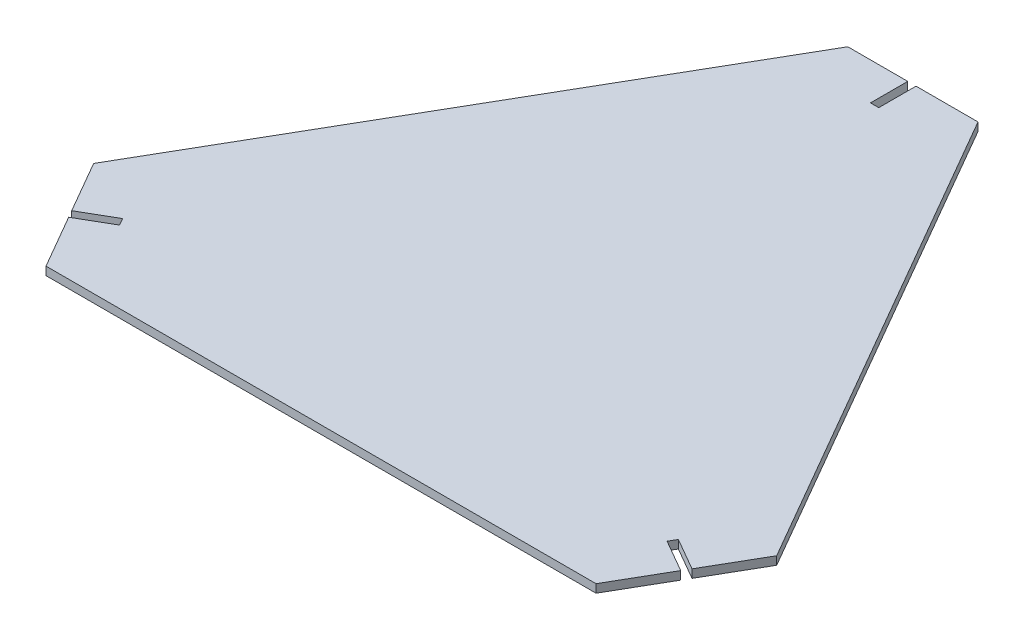
from build123d import *

# Parameters (mm, degrees)
SALIENTE_EXTRUIR1_DEPTH = 1.5
CORTAR_EXTRUIR1_DEPTH   = 3
MATRIZC1_COUNT          = 3
CORTAR_EXTRUIR4_REACH   = 5


with BuildPart() as part:
    # Croquis1 → Saliente-Extruir1 (new body, symmetric)
    with BuildSketch(Plane(origin=(0, 0, 0), x_dir=(1, 0, 0), z_dir=(0, 1, 0))):
        with BuildLine():
            Line((-129.903810568, -55), (-17.320508076, 140))
            ThreePointArc((-17.320508076, 140), (0, 150), (17.320508076, 140))
            Line((17.320508076, 140), (129.903810568, -55))
            ThreePointArc((129.903810568, -55), (129.903810568, -75), (112.583302492, -85))
            Line((112.583302492, -85), (-112.583302492, -85))
            ThreePointArc((-112.583302492, -85), (-129.903810568, -75), (-129.903810568, -55))
        make_face()
    extrude(amount=SALIENTE_EXTRUIR1_DEPTH, both=True)

    # Croquis2 → Cortar-Extruir1 (cut)
    with BuildSketch(Plane(origin=(0, 1.5, 0), x_dir=(1, 0, 0), z_dir=(0, 1, 0))):
        Polygon((107.503175473, -63.799038106), (109.003175473, -61.200961894), (100.342921435, -56.200961894), (98.842921435, -58.799038106), align=None)
        Polygon((113.784264386, -59.919872981), (116.382340598, -61.419872981), (121.382340598, -52.759618943), (118.784264386, -51.259618943), align=None)
        Polygon((117.663429511, -66.200961894), (116.163429511, -68.799038106), (124.823683549, -73.799038106), (126.323683549, -71.200961894), align=None)
        Polygon((111.382340598, -70.080127019), (108.784264386, -68.580127019), (103.784264386, -77.240381057), (106.382340598, -78.740381057), align=None)
    cortar_extruir1 = extrude(amount=-CORTAR_EXTRUIR1_DEPTH, mode=Mode.SUBTRACT)

    # MatrizC1: Cortar-Extruir1 ×3 about axis
    matrizc1_axis = Axis((-0.369121776, 0, -0.213112557), (0, 1, 0))
    for i in range(1, MATRIZC1_COUNT):
        add(cortar_extruir1.rotate(matrizc1_axis, i * 360 / MATRIZC1_COUNT), mode=Mode.SUBTRACT)

    # Croquis5 → Cortar-Extruir4 (cut, up to next)
    with BuildSketch(Plane(origin=(0, 1.5, 0), x_dir=(1, 0, 0), z_dir=(0, 1, 0)), mode=Mode.PRIVATE) as cortar_extruir4_sk1:
        Polygon((-123.633404248, -44.139337671), (-112.772507939, -62.950961894), (-109.741419026, -61.200961894), (-108.241419026, -63.799038106), (-111.272507939, -65.549038106), (-100.042489853, -85), (-147.224318643, -85), align=None)
    cortar_extruir4_tool1 = extrude(cortar_extruir4_sk1.sketch, amount=-CORTAR_EXTRUIR4_REACH, mode=Mode.PRIVATE) & part.part
    add(cortar_extruir4_tool1.solids().sort_by_distance((-123.491961, 1.5, 71.293524))[0], mode=Mode.SUBTRACT)
    # Croquis5 → Cortar-Extruir4 (cut, up to next)
    with BuildSketch(Plane(origin=(0, 1.5, 0), x_dir=(1, 0, 0), z_dir=(0, 1, 0)), mode=Mode.PRIVATE) as cortar_extruir4_sk2:
        Polygon((-1.869121776, 129.139337671), (-23.590914395, 129.139337671), (0, 170), (23.590914395, 129.139337671), (1.130878224, 129.139337671), (1.130878224, 125.639337671), (-1.869121776, 125.639337671), align=None)
    cortar_extruir4_tool2 = extrude(cortar_extruir4_sk2.sketch, amount=-CORTAR_EXTRUIR4_REACH, mode=Mode.PRIVATE) & part.part
    add(cortar_extruir4_tool2.solids().sort_by_distance((-0.003977, 1.5, -142.593938))[0], mode=Mode.SUBTRACT)
    # Croquis5 → Cortar-Extruir4 (cut, up to next)
    with BuildSketch(Plane(origin=(0, 1.5, 0), x_dir=(1, 0, 0), z_dir=(0, 1, 0)), mode=Mode.PRIVATE) as cortar_extruir4_sk3:
        Polygon((112.034264386, -62.950961894), (123.264282472, -43.5), (147.224318643, -85), (99.304246301, -85), (110.534264386, -65.549038106), (107.503175473, -63.799038106), (109.003175473, -61.200961894), align=None)
    cortar_extruir4_tool3 = extrude(cortar_extruir4_sk3.sketch, amount=-CORTAR_EXTRUIR4_REACH, mode=Mode.PRIVATE) & part.part
    add(cortar_extruir4_tool3.solids().sort_by_distance((123.123262, 1.5, 71.085248))[0], mode=Mode.SUBTRACT)


solid = part.part
